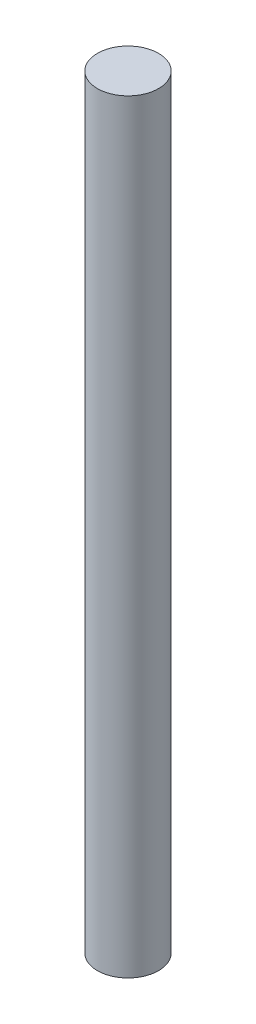
from build123d import *

# Parameters (mm, degrees)
CROQUIS2_R = 4


with BuildPart() as part:
    # Barrer1: sweep along a path in Croquis1
    with BuildLine(Plane.XY) as barrer1_path:
        Line((0, 0), (0, 100))
    # Croquis2 → Barrer1 (sweep)
    with BuildSketch(Plane(origin=(0, 0, 0), x_dir=(1, 0, 0), z_dir=(0, 1, 0))):
        Circle(CROQUIS2_R)
    sweep(path=barrer1_path.line)


solid = part.part
